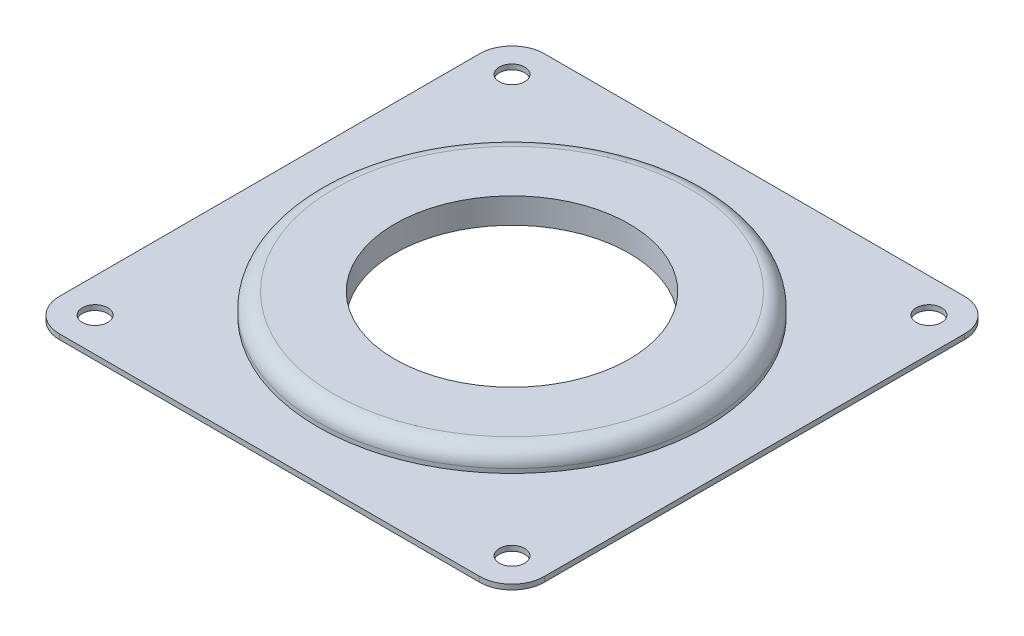
from build123d import *

# Parameters (mm, degrees)
SKETCH1_W           = 76.2
SKETCH1_H           = 76.2
SKETCH1_R           = 2.000000064
SKETCH1_R_2         = 18.415
BOSS_EXTRUDE1_DEPTH = 0.8
FILLET1_R           = 5.08
SKETCH2_R           = 30.48
SKETCH2_R_2         = 18.415
BOSS_EXTRUDE2_DEPTH = 3.2
FILLET2_R           = 2.54


with BuildPart() as part:
    # Sketch1 → Boss-Extrude1 (new body)
    with BuildSketch(Plane(origin=(0, 0, 0), x_dir=(1, 0, 0), z_dir=(0, 1, 0))):
        Rectangle(SKETCH1_W, SKETCH1_H)
        with Locations((-32.75, 32.75)):
            Circle(SKETCH1_R, mode=Mode.SUBTRACT)
        with Locations((32.75, 32.75)):
            Circle(SKETCH1_R, mode=Mode.SUBTRACT)
        with Locations((32.75, -32.75)):
            Circle(SKETCH1_R, mode=Mode.SUBTRACT)
        with Locations((-32.75, -32.75)):
            Circle(SKETCH1_R, mode=Mode.SUBTRACT)
        Circle(SKETCH1_R_2, mode=Mode.SUBTRACT)
    extrude(amount=BOSS_EXTRUDE1_DEPTH)

    # Fillet1
    fillet1_edges = [part.edges().sort_by_distance(p)[0] for p in [
        (38.1, 0.4, 38.1),
        (-38.1, 0.4, 38.1),
        (-38.1, 0.4, -38.1),
        (38.1, 0.4, -38.1),
    ]]
    fillet(fillet1_edges, radius=FILLET1_R)

    # Sketch2 → Boss-Extrude2 (add)
    with BuildSketch(Plane(origin=(0, 0.8, 0), x_dir=(1, 0, 0), z_dir=(0, 1, 0))):
        Circle(SKETCH2_R)
        Circle(SKETCH2_R_2, mode=Mode.SUBTRACT)
    extrude(amount=BOSS_EXTRUDE2_DEPTH)

    # Fillet2
    fillet2_edges = [part.edges().sort_by_distance(p)[0] for p in [
        (-30.48, 4, 0),
    ]]
    fillet(fillet2_edges, radius=FILLET2_R)


solid = part.part
